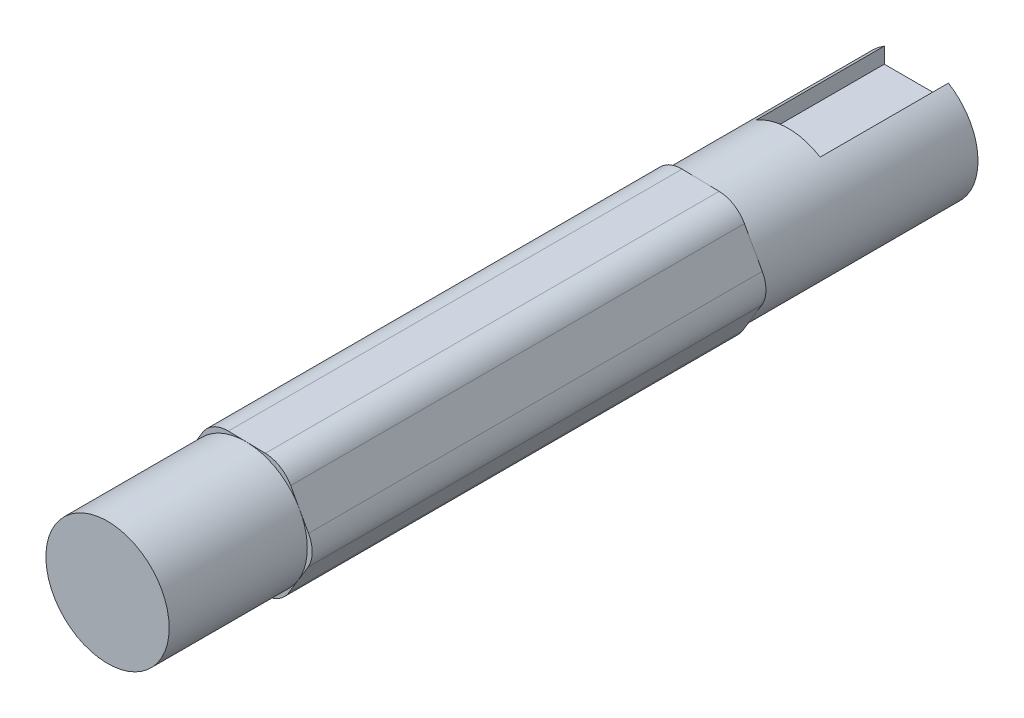
from build123d import *

# Parameters (mm, degrees)
SKETCH1_R                = 6.25
BOSS_EXTRUDE1_DEPTH      = 37
BOSS_EXTRUDE1_DEPTH_BACK = 45
SKETCH4_W                = 6.5
SKETCH4_H                = 5
CUT_EXTRUDE1_DEPTH       = 13
BOSS_EXTRUDE2_DEPTH      = 46
FILLET1_R                = 3


with BuildPart() as part:
    # Sketch1 → Boss-Extrude1 (new body, two sides)
    with BuildSketch(Plane.XY) as boss_extrude1_sk:
        Circle(SKETCH1_R)
    extrude(amount=BOSS_EXTRUDE1_DEPTH)
    extrude(boss_extrude1_sk.sketch, amount=-BOSS_EXTRUDE1_DEPTH_BACK)

    # Sketch4 → Cut-Extrude1 (cut)
    with BuildSketch(Plane(origin=(0, 0, -45), x_dir=(-1, 0, 0), z_dir=(0, 0, -1))):
        with Locations((0, 6.25)):
            Rectangle(SKETCH4_W, SKETCH4_H)
    extrude(amount=-CUT_EXTRUDE1_DEPTH, mode=Mode.SUBTRACT)

    # Sketch5 → Boss-Extrude2 (add)
    with BuildSketch(Plane.XY.offset(-23)):
        Polygon((3.732897661, 6.176472163), (-3.482532969, 6.321020286), (-7.21543063, 0.144548123), (-3.732897661, -6.176472163), (3.482532969, -6.321020286), (7.21543063, -0.144548123), align=None)
    extrude(amount=BOSS_EXTRUDE2_DEPTH)

    # Fillet1
    fillet1_edges = [part.edges().sort_by_distance(p)[0] for p in [
        (7.21543063, -0.144548123, 0),
        (3.732897661, 6.176472163, 0),
        (-3.482532969, 6.321020286, 0),
        (-7.21543063, 0.144548123, 0),
        (-3.732897661, -6.176472163, 0),
        (3.482532969, -6.321020286, 0),
    ]]
    fillet(fillet1_edges, radius=FILLET1_R)


solid = part.part
